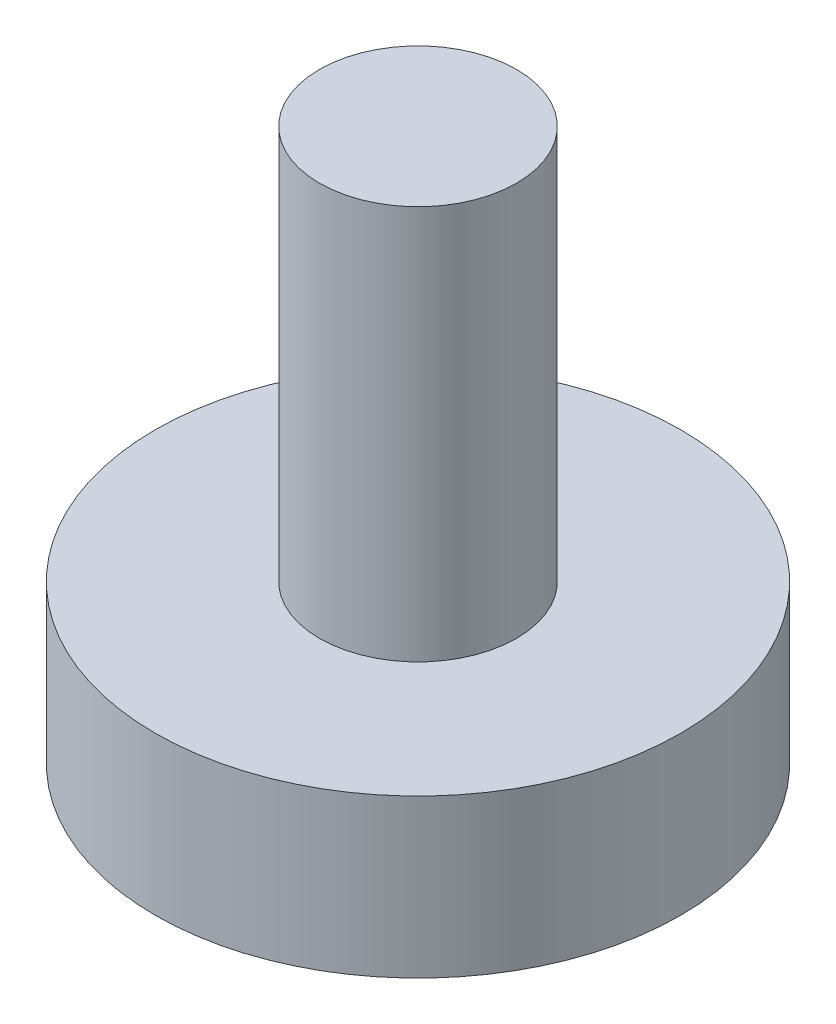
from build123d import *

# Parameters (mm, degrees)
CROQUIS1_R              = 10
SALIENTE_EXTRUIR1_DEPTH = 6
CROQUIS2_R              = 3.75
SALIENTE_EXTRUIR2_DEPTH = 15


with BuildPart() as part:
    # Croquis1 → Saliente-Extruir1 (new body)
    with BuildSketch(Plane(origin=(0, 0, 0), x_dir=(1, 0, 0), z_dir=(0, 1, 0))):
        Circle(CROQUIS1_R)
    extrude(amount=SALIENTE_EXTRUIR1_DEPTH)

    # Croquis2 → Saliente-Extruir2 (add)
    with BuildSketch(Plane(origin=(0, 6, 0), x_dir=(1, 0, 0), z_dir=(0, 1, 0))):
        Circle(CROQUIS2_R)
    extrude(amount=SALIENTE_EXTRUIR2_DEPTH)


solid = part.part
